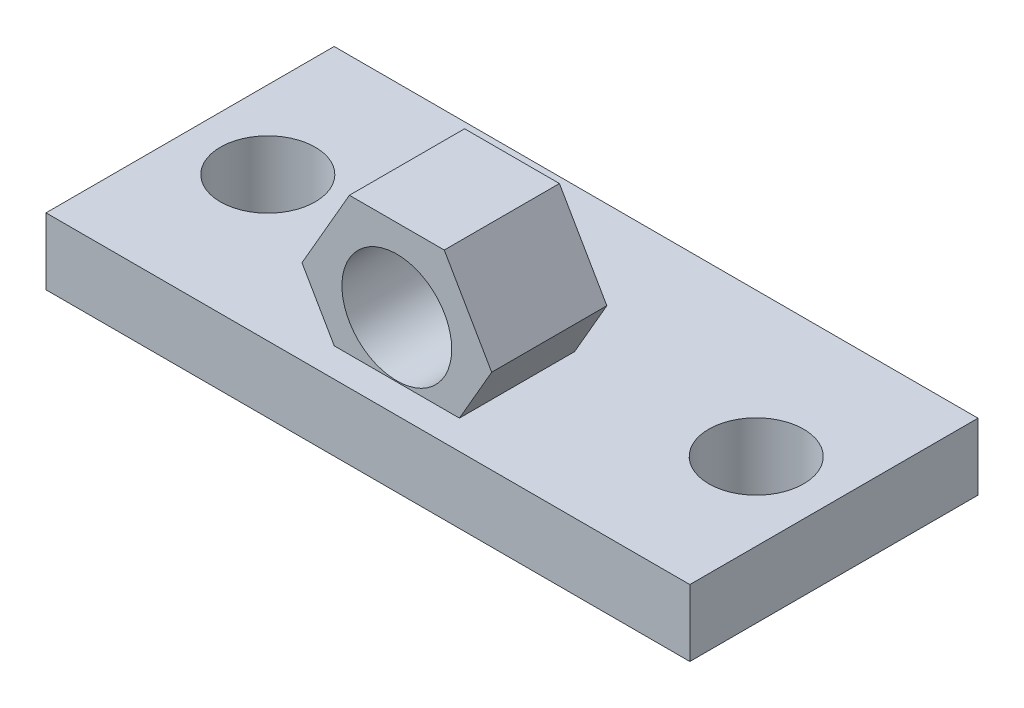
from build123d import *

# Parameters (mm, degrees)
CROQUIS1_W                 = 48.280426218
CROQUIS1_H                 = 21.608022922
SALIENTE_EXTRUIR1_DEPTH    = 5
CROQUIS2_R                 = 2.974152903
CORTAR_EXTRUIR1_DEPTH      = 15
CORTAR_EXTRUIR1_DEPTH_BACK = 23
CROQUIS3_R                 = 3.556
CORTAR_EXTRUIR2_DEPTH      = 31.496
CORTAR_EXTRUIR2_DEPTH_BACK = 20.828
CROQUIS4_R                 = 3.556
CORTAR_EXTRUIR3_DEPTH      = 8.636
CORTAR_EXTRUIR3_DEPTH_BACK = 20.828
CROQUIS5_R                 = 4.117290135
SALIENTE_EXTRUIR2_DEPTH    = 8.636


with BuildPart() as part:
    # Croquis1 → Saliente-Extruir1 (new body)
    with BuildSketch(Plane(origin=(0, 0, 0), x_dir=(1, 0, 0), z_dir=(0, 1, 0))):
        Rectangle(CROQUIS1_W, CROQUIS1_H)
    extrude(amount=SALIENTE_EXTRUIR1_DEPTH)

    # Croquis2 → Cortar-Extruir1 (cut, two sides)
    with BuildSketch(Plane(origin=(0, 0, 0), x_dir=(1, 0, 0), z_dir=(0, 1, 0))) as cortar_extruir1_sk:
        with Locations((18.312839715, 0)):
            Circle(CROQUIS2_R)
        with Locations((-18.312839715, 0)):
            Circle(CROQUIS2_R)
    extrude(amount=CORTAR_EXTRUIR1_DEPTH, mode=Mode.SUBTRACT)
    extrude(cortar_extruir1_sk.sketch, amount=-CORTAR_EXTRUIR1_DEPTH_BACK, mode=Mode.SUBTRACT)

    # Croquis3 → Cortar-Extruir2 (cut, two sides)
    with BuildSketch(Plane(origin=(0, 0, 0), x_dir=(1, 0, 0), z_dir=(0, 1, 0))) as cortar_extruir2_sk:
        with Locations((18.312839715, 0)):
            Circle(CROQUIS3_R)
    extrude(amount=CORTAR_EXTRUIR2_DEPTH, mode=Mode.SUBTRACT)
    extrude(cortar_extruir2_sk.sketch, amount=-CORTAR_EXTRUIR2_DEPTH_BACK, mode=Mode.SUBTRACT)

    # Croquis4 → Cortar-Extruir3 (cut, two sides)
    with BuildSketch(Plane(origin=(0, 5, 0), x_dir=(1, 0, 0), z_dir=(0, 1, 0))) as cortar_extruir3_sk:
        with Locations((-18.312839715, 0)):
            Circle(CROQUIS4_R)
    extrude(amount=CORTAR_EXTRUIR3_DEPTH, mode=Mode.SUBTRACT)
    extrude(cortar_extruir3_sk.sketch, amount=-CORTAR_EXTRUIR3_DEPTH_BACK, mode=Mode.SUBTRACT)

    # Croquis5 → Saliente-Extruir2 (add)
    with BuildSketch(Plane.XY):
        Polygon((7.112251642, 9.190063188), (3.556125821, 15.349453788), (-3.556125821, 15.349453788), (-7.112251642, 9.190063188), (-3.556125821, 3.030672588), (3.556125821, 3.030672588), align=None)
        with Locations((0, 9.190063188)):
            Circle(CROQUIS5_R, mode=Mode.SUBTRACT)
    extrude(amount=SALIENTE_EXTRUIR2_DEPTH)


solid = part.part
